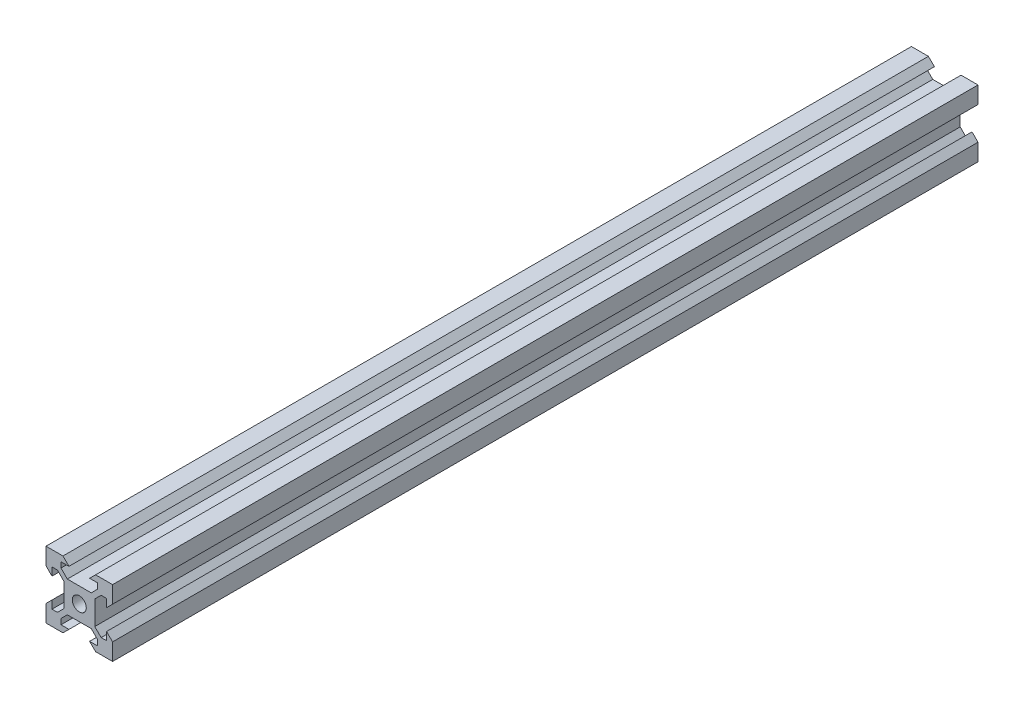
from build123d import *

# Parameters (mm, degrees)
SKETCH1_R           = 2.1
BOSS_EXTRUDE1_DEPTH = 130


with BuildPart() as part:
    # Sketch1 → Boss-Extrude1 (new body, symmetric)
    with BuildSketch(Plane.XY):
        Polygon((5.499339828, 6.56), (3.59, 4.650660172), (-3.59, 4.650660172), (-5.499339828, 6.56), (-5.499339828, 8.2), (-3.1, 8.2), (-4.9, 10), (-10, 10), (-10, 4.9), (-8.2, 3.1), (-8.2, 5.499339828), (-6.56, 5.499339828), (-4.650660172, 3.59), (-4.650660172, -3.59), (-6.56, -5.499339828), (-8.2, -5.499339828), (-8.2, -3.1), (-10, -4.9), (-10, -10), (-4.9, -10), (-3.1, -8.2), (-5.499339828, -8.2), (-5.499339828, -6.56), (-3.59, -4.650660172), (3.59, -4.650660172), (5.499339828, -6.56), (5.499339828, -8.2), (3.1, -8.2), (4.9, -10), (10, -10), (10, -4.9), (8.2, -3.1), (8.2, -5.499339828), (6.56, -5.499339828), (4.650660172, -3.59), (4.650660172, 3.59), (6.56, 5.499339828), (8.2, 5.499339828), (8.2, 3.1), (10, 4.9), (10, 10), (4.9, 10), (3.1, 8.2), (5.499339828, 8.2), align=None)
        Circle(SKETCH1_R, mode=Mode.SUBTRACT)
    extrude(amount=BOSS_EXTRUDE1_DEPTH, both=True)


solid = part.part
